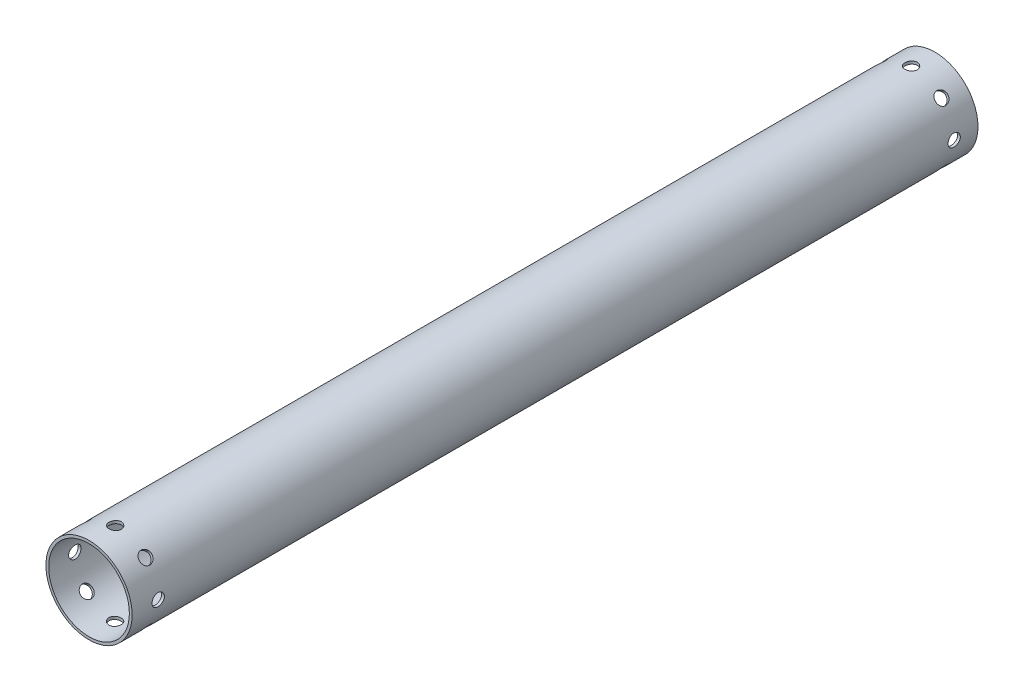
from build123d import *

# Parameters (mm, degrees)
CROQUIS1_R              = 28.0509
CROQUIS1_R_2            = 26.2509
SALIENTE_EXTRUIR1_DEPTH = 550.5
MATRIZC1_COUNT          = 8


with BuildPart() as part:
    # Croquis1 → Saliente-Extruir1 (new body)
    with BuildSketch(Plane.XY):
        Circle(CROQUIS1_R)
        Circle(CROQUIS1_R_2, mode=Mode.SUBTRACT)
    extrude(amount=-SALIENTE_EXTRUIR1_DEPTH)

    # Croquis13 → Ø8.0mm Dowel Hole1 (revolve, cut)
    with BuildSketch(Plane(origin=(0, 28.0509, -535), x_dir=(0, 0, 1), z_dir=(1, 0, 0))):
        Polygon((0, 0), (0, 9.403442476), (4, 7), (4, 0), align=None)
    f_8_0mm_dowel_hole1 = revolve(axis=Axis((0, 34.4009, -535), (0, -1, 0)), mode=Mode.SUBTRACT)

    # Croquis17 → Ø8.0mm Dowel Hole2 (revolve, cut)
    with BuildSketch(Plane(origin=(0, 28.0509, -17), x_dir=(0, 0, 1), z_dir=(1, 0, 0))):
        Polygon((0, 0), (0, 9.403442476), (4, 7), (4, 0), align=None)
    f_8_0mm_dowel_hole2 = revolve(axis=Axis((0, 34.4009, -17), (0, -1, 0)), mode=Mode.SUBTRACT)

    # MatrizC1: Ø8.0mm Dowel Hole1, Ø8.0mm Dowel Hole2 ×8 about axis
    matrizc1_axis = Axis((0, 0, -550.5), (0, 0, 1))
    for i in range(1, MATRIZC1_COUNT):
        add(f_8_0mm_dowel_hole1.rotate(matrizc1_axis, i * 360 / MATRIZC1_COUNT), mode=Mode.SUBTRACT)
        add(f_8_0mm_dowel_hole2.rotate(matrizc1_axis, i * 360 / MATRIZC1_COUNT), mode=Mode.SUBTRACT)


solid = part.part
